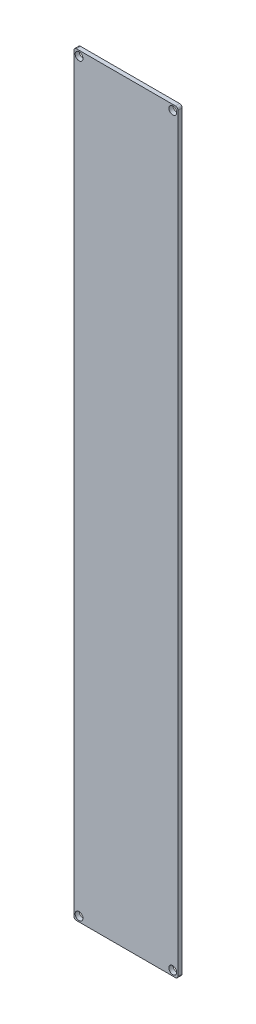
from build123d import *

# Parameters (mm, degrees)
SKETCH1_W           = 40
SKETCH1_H           = 290
BOSS_EXTRUDE1_DEPTH = 1.6
SKETCH2_R           = 1.5
CUT_EXTRUDE1_DEPTH  = 2.6
FILLET1_R           = 1


with BuildPart() as part:
    # Sketch1 → Boss-Extrude1 (new body)
    with BuildSketch(Plane.XY):
        with Locations((-15.538461538, -65.630769231)):
            Rectangle(SKETCH1_W, SKETCH1_H)
    extrude(amount=BOSS_EXTRUDE1_DEPTH)

    # Sketch2 → Cut-Extrude1 (cut, through all)
    with BuildSketch(Plane.XY.offset(1.6)):
        with Locations((-33.538461538, 77.369230769)):
            Circle(SKETCH2_R)
        with Locations((2.461538462, 77.369230769)):
            Circle(SKETCH2_R)
        with Locations((-33.538461538, -208.630769231)):
            Circle(SKETCH2_R)
        with Locations((2.461538462, -208.630769231)):
            Circle(SKETCH2_R)
    extrude(amount=-CUT_EXTRUDE1_DEPTH, mode=Mode.SUBTRACT)

    # Fillet1
    fillet1_edges = [part.edges().sort_by_distance(p)[0] for p in [
        (-35.538461538, 79.369230769, 0.8),
        (4.461538462, 79.369230769, 0.8),
        (4.461538462, -210.630769231, 0.8),
        (-35.538461538, -210.630769231, 0.8),
    ]]
    fillet(fillet1_edges, radius=FILLET1_R)


solid = part.part
